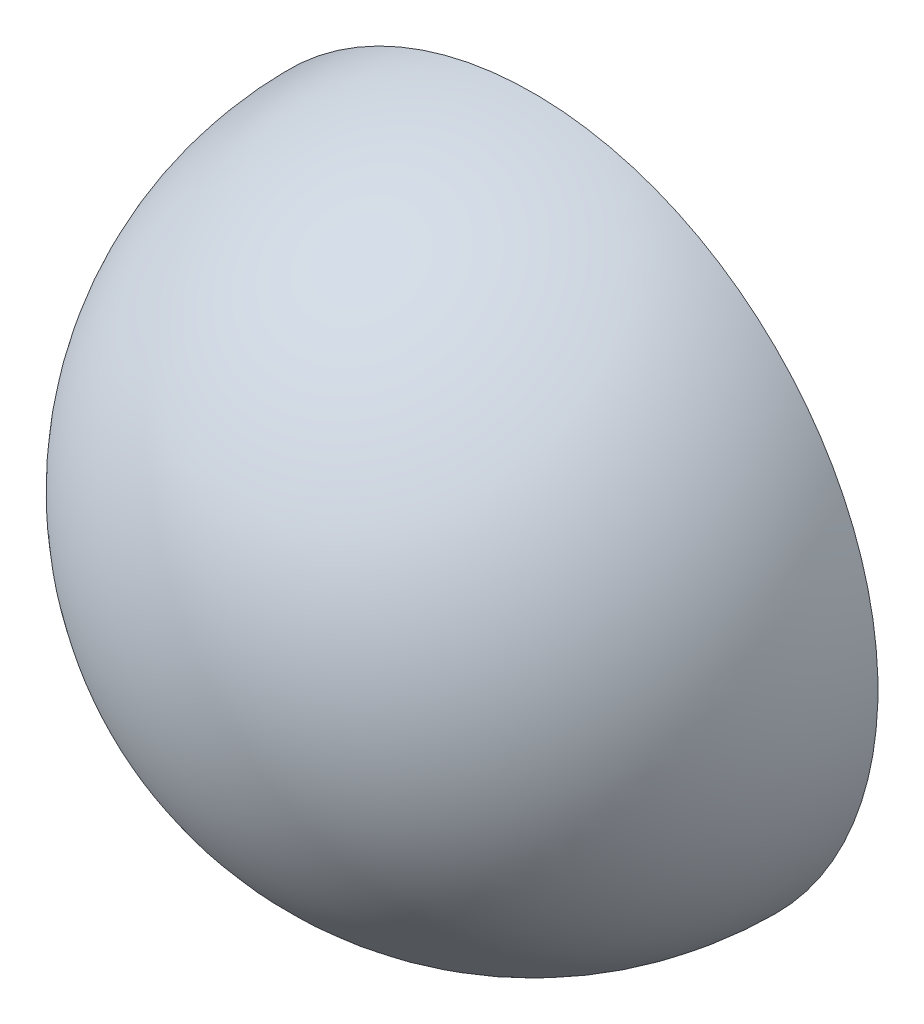
from build123d import *

# Parameters (mm, degrees)
REVOLVE1_ANGLE = 180


with BuildPart() as part:
    # Sketch1 → Revolve1 (revolve)
    with BuildSketch(Plane.XY):
        with BuildLine():
            Line((-100, 0), (-98, 0))
            ThreePointArc((-98, 0), (-50, 48), (-2, 0))
            Line((-2, 0), (0, 0))
            ThreePointArc((0, 0), (-50, 50), (-100, 0))
        make_face()
    revolve(axis=Axis((-98, 0, 0), (1, 0, 0)), revolution_arc=REVOLVE1_ANGLE)


solid = part.part
